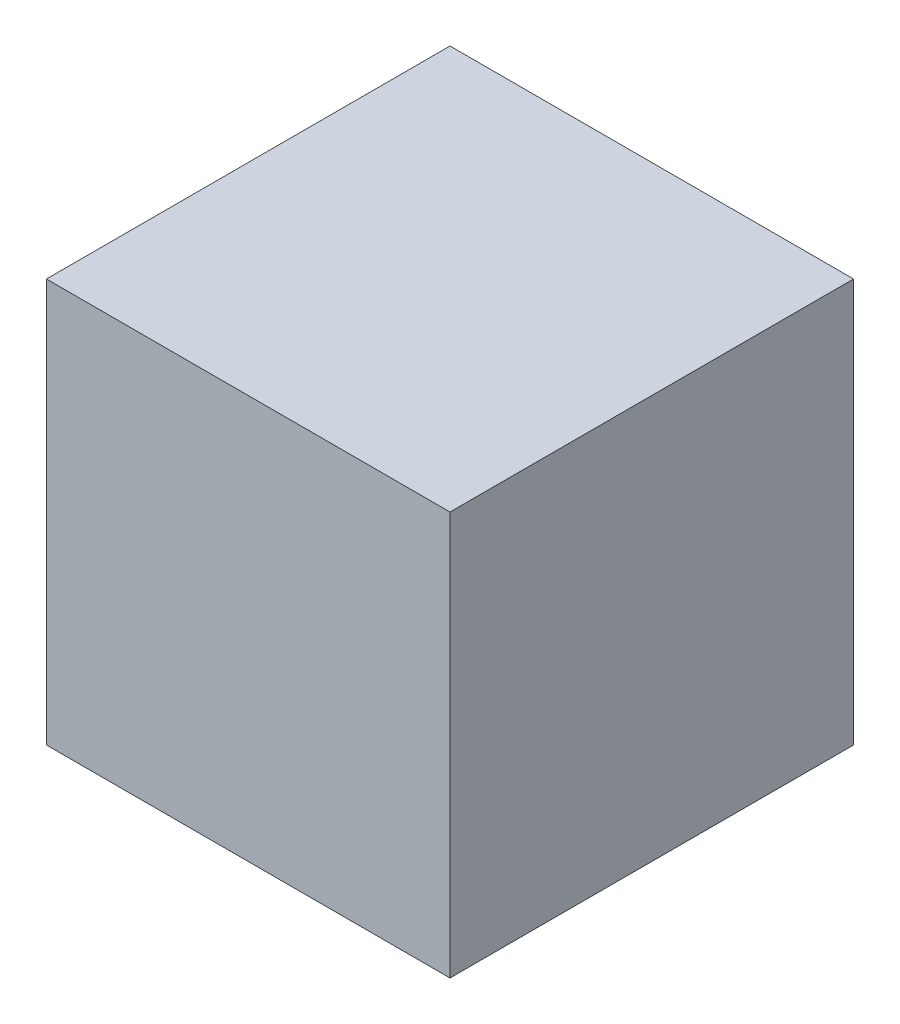
from build123d import *

# Parameters (mm, degrees)
SKETCH1_W           = 57.658
SKETCH1_H           = 57.658
BOSS_EXTRUDE1_DEPTH = 57.658


with BuildPart() as part:
    # Sketch1 → Boss-Extrude1 (new body)
    with BuildSketch(Plane(origin=(0, 0, 0), x_dir=(1, 0, 0), z_dir=(0, 1, 0))):
        Rectangle(SKETCH1_W, SKETCH1_H)
    extrude(amount=BOSS_EXTRUDE1_DEPTH)


solid = part.part
